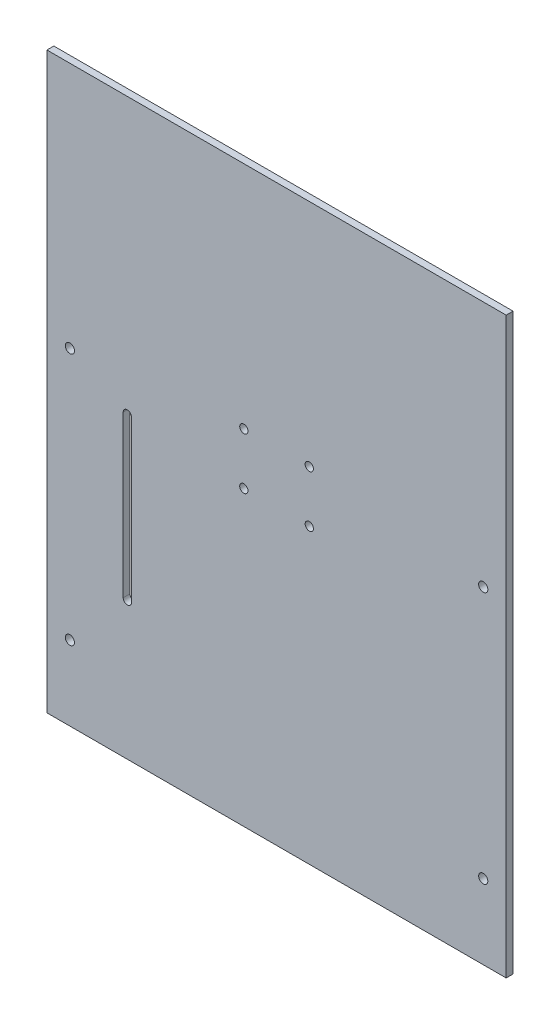
from build123d import *

# Parameters (mm, degrees)
ESBO_O1_W                = 200
ESBO_O1_H                = 250
ESBO_O1_R                = 1.8
ESBO_O1_R_2              = 2
RESSALTO_EXTRUS_O1_DEPTH = 3


with BuildPart() as part:
    # Esboço1 → Ressalto-extrusão1 (new body)
    with BuildSketch(Plane.XY):
        Rectangle(ESBO_O1_W, ESBO_O1_H)
        with Locations((-14.25, 25)):
            Circle(ESBO_O1_R, mode=Mode.SUBTRACT)
        with Locations((14.25, 25)):
            Circle(ESBO_O1_R, mode=Mode.SUBTRACT)
        with Locations((14.25, 2.5)):
            Circle(ESBO_O1_R, mode=Mode.SUBTRACT)
        with Locations((-14.25, 2.5)):
            Circle(ESBO_O1_R, mode=Mode.SUBTRACT)
        with Locations((-90, -92.5)):
            Circle(ESBO_O1_R_2, mode=Mode.SUBTRACT)
        with Locations((-90, 17.5)):
            Circle(ESBO_O1_R_2, mode=Mode.SUBTRACT)
        with Locations((90, 17.5)):
            Circle(ESBO_O1_R_2, mode=Mode.SUBTRACT)
        with Locations((90, -92.5)):
            Circle(ESBO_O1_R_2, mode=Mode.SUBTRACT)
        with BuildLine():
            Line((-63.2, 5), (-63.2, -65))
            ThreePointArc((-63.2, -65), (-65, -66.8), (-66.8, -65))
            Line((-66.8, -65), (-66.8, 5))
            ThreePointArc((-66.8, 5), (-65, 6.8), (-63.2, 5))
        make_face(mode=Mode.SUBTRACT)
    extrude(amount=RESSALTO_EXTRUS_O1_DEPTH)


solid = part.part
